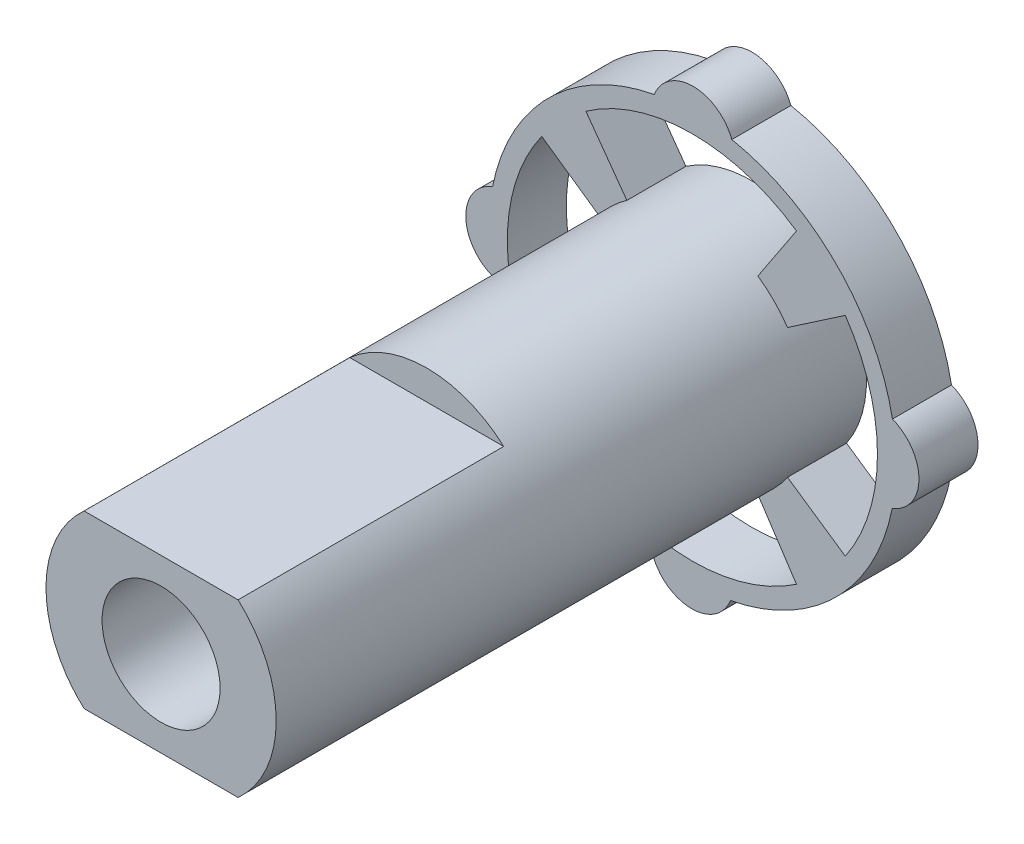
from build123d import *

# Parameters (mm, degrees)
SKETCH_1_R          = 1.95
SKETCH_1_R_2        = 1
EXTRUDE_1_DEPTH     = 5
EXTRUDE_3_DEPTH     = 1
SKETCH_5_W          = 3.686325021
SKETCH_5_H          = 0.905885224
SKETCH_5_W_2        = 4.457672836
SKETCH_5_H_2        = 1.506818987
CUT_EXTRUDE_4_DEPTH = 4.5


with BuildPart() as part:
    # 草图1 → 凸台-拉伸1 (new body, symmetric)
    with BuildSketch(Plane.XY):
        Circle(SKETCH_1_R)
        Circle(SKETCH_1_R_2, mode=Mode.SUBTRACT)
    extrude(amount=EXTRUDE_1_DEPTH, both=True)

    # 草图3 → 凸台-拉伸3 (add)
    with BuildSketch(Plane(origin=(0, 0, -5), x_dir=(-1, 0, 0), z_dir=(0, 0, -1))):
        with BuildLine():
            ThreePointArc((-0.668047872, 3.384702652), (-2.447870462, 2.431137635), (-3.389205192, 0.644816382))
            ThreePointArc((-3.389205192, 0.644816382), (-3.838268125, -0.013163552), (-3.384702652, -0.668047872))
            ThreePointArc((-3.384702652, -0.668047872), (-2.431137635, -2.447870462), (-0.644816382, -3.389205192))
            ThreePointArc((-0.644816382, -3.389205192), (0.013163552, -3.838268125), (0.668047872, -3.384702652))
            ThreePointArc((0.668047872, -3.384702652), (2.447870462, -2.431137635), (3.389205192, -0.644816382))
            ThreePointArc((3.389205192, -0.644816382), (3.838268125, 0.013163552), (3.384702652, 0.668047872))
            ThreePointArc((3.384702652, 0.668047872), (2.431137635, 2.447870462), (0.644816382, 3.389205192))
            ThreePointArc((0.644816382, 3.389205192), (-0.013163552, 3.838268125), (-0.668047872, 3.384702652))
        make_face()
        with BuildLine():
            Line((2.551831088, 1.821511161), (1.580005505, 1.142839711))
            ThreePointArc((1.580005505, 1.142839711), (1.364402664, 1.393163799), (1.109636091, 1.603498596))
            Line((1.109636091, 1.603498596), (1.804122226, 2.564154403))
            ThreePointArc((1.804122226, 2.564154403), (0.024621795, 3.135145702), (-1.763627121, 2.592173641))
            Line((-1.763627121, 2.592173641), (-1.109636091, 1.603498596))
            ThreePointArc((-1.109636091, 1.603498596), (-1.383616658, 1.374083311), (-1.611132184, 1.098523138))
            Line((-1.611132184, 1.098523138), (-2.590192379, 1.766535663))
            ThreePointArc((-2.590192379, 1.766535663), (-3.135242384, 0), (-2.590192379, -1.766535663))
            Line((-2.590192379, -1.766535663), (-1.611132184, -1.098523138))
            ThreePointArc((-1.611132184, -1.098523138), (-1.383616658, -1.374083311), (-1.109636091, -1.603498596))
            Line((-1.109636091, -1.603498596), (-1.763627121, -2.592173641))
            ThreePointArc((-1.763627121, -2.592173641), (0, -3.135242384), (1.763627121, -2.592173641))
            Line((1.763627121, -2.592173641), (1.109636091, -1.603498596))
            ThreePointArc((1.109636091, -1.603498596), (1.383616658, -1.374083311), (1.611132184, -1.098523138))
            Line((1.611132184, -1.098523138), (2.590192379, -1.766535663))
            ThreePointArc((2.590192379, -1.766535663), (3.135063211, 0.033518256), (2.551831088, 1.821511161))
        make_face(mode=Mode.SUBTRACT)
    extrude(amount=-EXTRUDE_3_DEPTH)

    # 草图5 → 切除-拉伸4 (cut)
    with BuildSketch(Plane.XY.offset(5)):
        with Locations((-0.148639524, 1.902942612)):
            Rectangle(SKETCH_5_W, SKETCH_5_H)
        with Locations((0.156311938, -2.203409494)):
            Rectangle(SKETCH_5_W_2, SKETCH_5_H_2)
    extrude(amount=-CUT_EXTRUDE_4_DEPTH, mode=Mode.SUBTRACT)


solid = part.part
